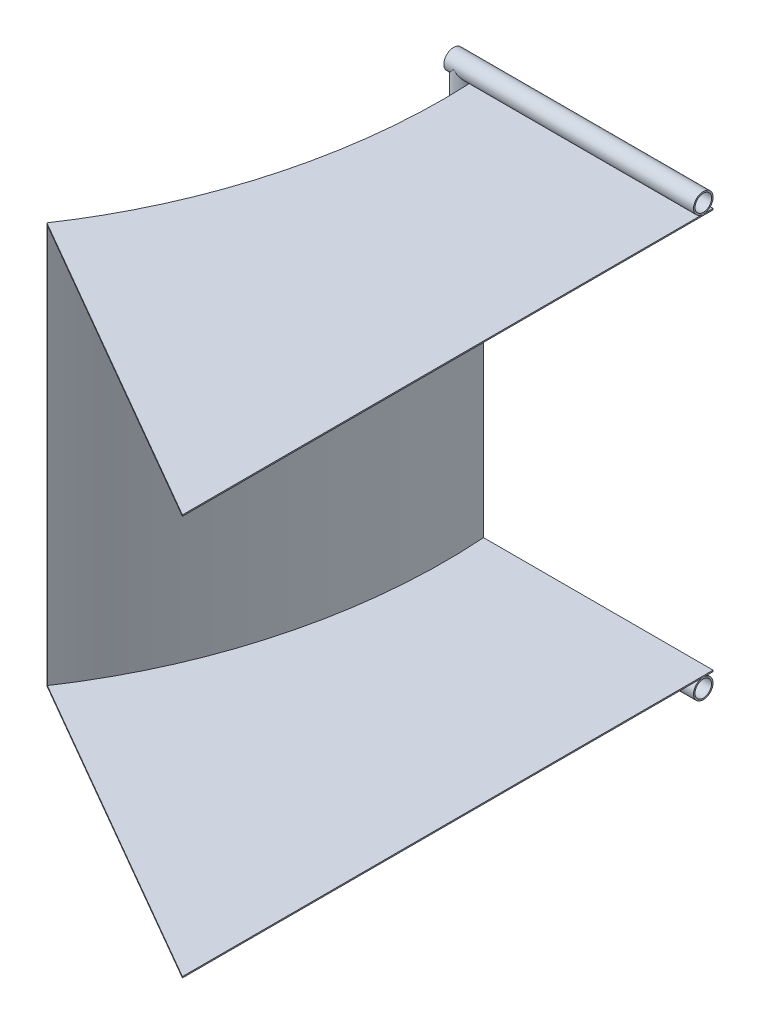
from build123d import *

# Parameters (mm, degrees)
BOSS_EXTRUDE1_DEPTH      = 325
SHELL1_T                 = -1.016
SKETCH2_R                = 7.9375
BOSS_EXTRUDE2_DEPTH      = 202.3
SKETCH3_R                = 6.6929
CUT_EXTRUDE1_DEPTH       = 260.807621235
SKETCH4_R                = 7.9375
SKETCH4_R_2              = 6.6929
BOSS_EXTRUDE3_DEPTH      = 15.875
BOSS_EXTRUDE3_DEPTH_BACK = 340.875
SKETCH6_R                = 7.9375
SKETCH6_R_2              = 6.6929
BOSS_EXTRUDE9_DEPTH      = 0.0001
BOSS_EXTRUDE9_DEPTH_BACK = 202.3
CUT_EXTRUDE2_DEPTH       = 260.807621235


with BuildPart() as part:
    # Sketch1 → Boss-Extrude1 (new body)
    with BuildSketch(Plane(origin=(0, 0, 0), x_dir=(1, 0, 0), z_dir=(0, 1, 0))):
        with BuildLine():
            Line((0, 0), (0, 430))
            Line((0, 430), (-187, 430))
            add(Edge.make_bspline(
                [(-187, 430), (-180.049319148, 332.332930929), (-204.798877093, 231.689816753), (-259.807621135, 150)],
                knots=[0, 0, 0, 0, 1, 1, 1, 1], degree=3))
            Line((-259.807621135, 150), (0, 0))
        make_face()
    extrude(amount=BOSS_EXTRUDE1_DEPTH)

    # Shell1
    shell1_openings = [part.faces().sort_by_distance(p)[0] for p in [
        (-93.5, 162.5, -430),
        (0, 162.5, -215),
        (-129.903810568, 162.5, -75),
    ]]
    offset(amount=SHELL1_T, openings=shell1_openings, kind=Kind.INTERSECTION)

    # Sketch4 → Boss-Extrude3 (add, two sides)
    with BuildSketch(Plane(origin=(0, 325, 0), x_dir=(-1, 0, 0), z_dir=(0, 1, 0))) as boss_extrude3_sk:
        with Locations((194.354011633, -422.019061054)):
            Circle(SKETCH4_R)
        with Locations((194.354011633, -422.019061054)):
            Circle(SKETCH4_R_2, mode=Mode.SUBTRACT)
    extrude(amount=BOSS_EXTRUDE3_DEPTH)
    extrude(boss_extrude3_sk.sketch, amount=-BOSS_EXTRUDE3_DEPTH_BACK)

    # Sketch7 → Cut-Extrude2 (cut, through all)
    with BuildSketch(Plane(origin=(0, 0, 0), x_dir=(0, 0, -1), z_dir=(1, 0, 0))):
        with BuildLine():
            Line((414.125, 332.9375), (402.216319392, 332.9375))
            Line((402.216319392, 332.9375), (402.216319392, 354.156251259))
            Line((402.216319392, 354.156251259), (446.927199566, 354.156251259))
            Line((446.927199566, 354.156251259), (446.927199566, 332.9375))
            Line((446.927199566, 332.9375), (430, 332.9375))
            ThreePointArc((430, 332.9375), (422.0625, 325), (414.125, 332.9375))
        make_face()
        with BuildLine():
            Line((414.073884985, -7.888658782), (410.063917237, -7.888658782))
            Line((410.063917237, -7.888658782), (410.063917237, -17.848986148))
            Line((410.063917237, -17.848986148), (432.903222186, -17.848986148))
            Line((432.903222186, -17.848986148), (432.903222186, -7.888658782))
            Line((432.903222186, -7.888658782), (429.948884985, -7.888658782))
            ThreePointArc((429.948884985, -7.888658782), (422.011384985, 0.048841218), (414.073884985, -7.888658782))
        make_face()
    extrude(amount=-CUT_EXTRUDE2_DEPTH, mode=Mode.SUBTRACT)


with BuildPart() as body_2:
    # Sketch2 → Boss-Extrude2 (new body)
    with BuildSketch(Plane(origin=(0, 0, 0), x_dir=(0, 0, -1), z_dir=(1, 0, 0))):
        with Locations((422.0625, 332.9375)):
            Circle(SKETCH2_R)
    extrude(amount=-BOSS_EXTRUDE2_DEPTH)

    # Sketch3 → Cut-Extrude1 (cut, through all)
    with BuildSketch(Plane(origin=(0, 0, 0), x_dir=(0, 0, -1), z_dir=(1, 0, 0))):
        with Locations((422.0625, 332.9375)):
            Circle(SKETCH3_R)
    extrude(amount=-CUT_EXTRUDE1_DEPTH, mode=Mode.SUBTRACT)


with BuildPart() as body_3:
    # Sketch6 → Boss-Extrude9 (new body, two sides)
    with BuildSketch(Plane(origin=(0, 0, 0), x_dir=(0, 0, -1), z_dir=(1, 0, 0))) as boss_extrude9_sk:
        with Locations((422.011384985, -7.888658782)):
            Circle(SKETCH6_R)
        with Locations((422.011384985, -7.888658782)):
            Circle(SKETCH6_R_2, mode=Mode.SUBTRACT)
    extrude(amount=BOSS_EXTRUDE9_DEPTH)
    extrude(boss_extrude9_sk.sketch, amount=-BOSS_EXTRUDE9_DEPTH_BACK)


solid = Compound([part.part, body_2.part, body_3.part])
